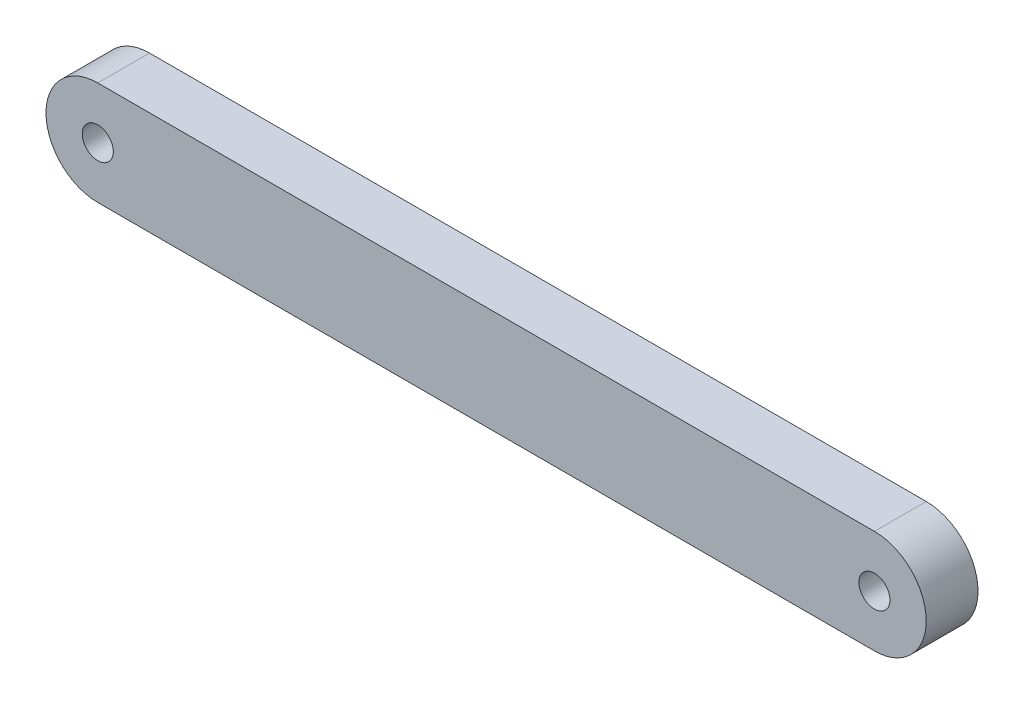
from build123d import *

# Parameters (mm, degrees)
BOSS_EXTRUDE1_DEPTH = 25
SKETCH2_R           = 15
CUT_EXTRUDE1_DEPTH  = 431.84219849


with BuildPart() as part:
    # Sketch1 → Boss-Extrude1 (new, symmetric)
    with BuildSketch(Plane.XY):
        with BuildLine():
            Line((-375, 50), (375, 50))
            ThreePointArc((375, 50), (425, 0), (375, -50))
            Line((375, -50), (-375, -50))
            ThreePointArc((-375, -50), (-425, 0), (-375, 50))
        make_face()
    extrude(amount=BOSS_EXTRUDE1_DEPTH, both=True)

    # Sketch2 → Cut-Extrude1 (cut, through all)
    with BuildSketch(Plane.XY.offset(25)):
        with Locations((-375, 0)):
            Circle(SKETCH2_R)
        with Locations((375, 0)):
            Circle(SKETCH2_R)
    extrude(amount=-CUT_EXTRUDE1_DEPTH, mode=Mode.SUBTRACT)


solid = part.part
